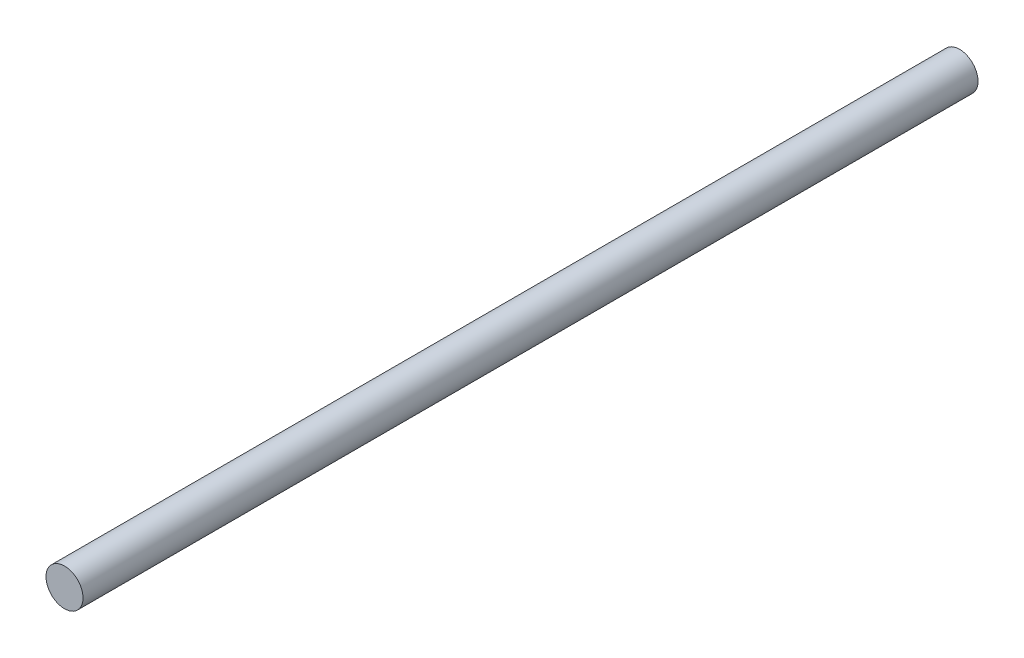
from build123d import *

# Parameters (mm, degrees)
SKETCH1_R           = 6
BOSS_EXTRUDE1_DEPTH = 250
SKETCH2_R           = 6
BOSS_EXTRUDE2_DEPTH = 40


with BuildPart() as part:
    # Sketch1 → Boss-Extrude1 (new body)
    with BuildSketch(Plane.XY):
        Circle(SKETCH1_R)
    extrude(amount=BOSS_EXTRUDE1_DEPTH)

    # Sketch2 → Boss-Extrude2 (add)
    with BuildSketch(Plane(origin=(0, 0, 0), x_dir=(-1, 0, 0), z_dir=(0, 0, -1))):
        Circle(SKETCH2_R)
    extrude(amount=BOSS_EXTRUDE2_DEPTH)


solid = part.part
